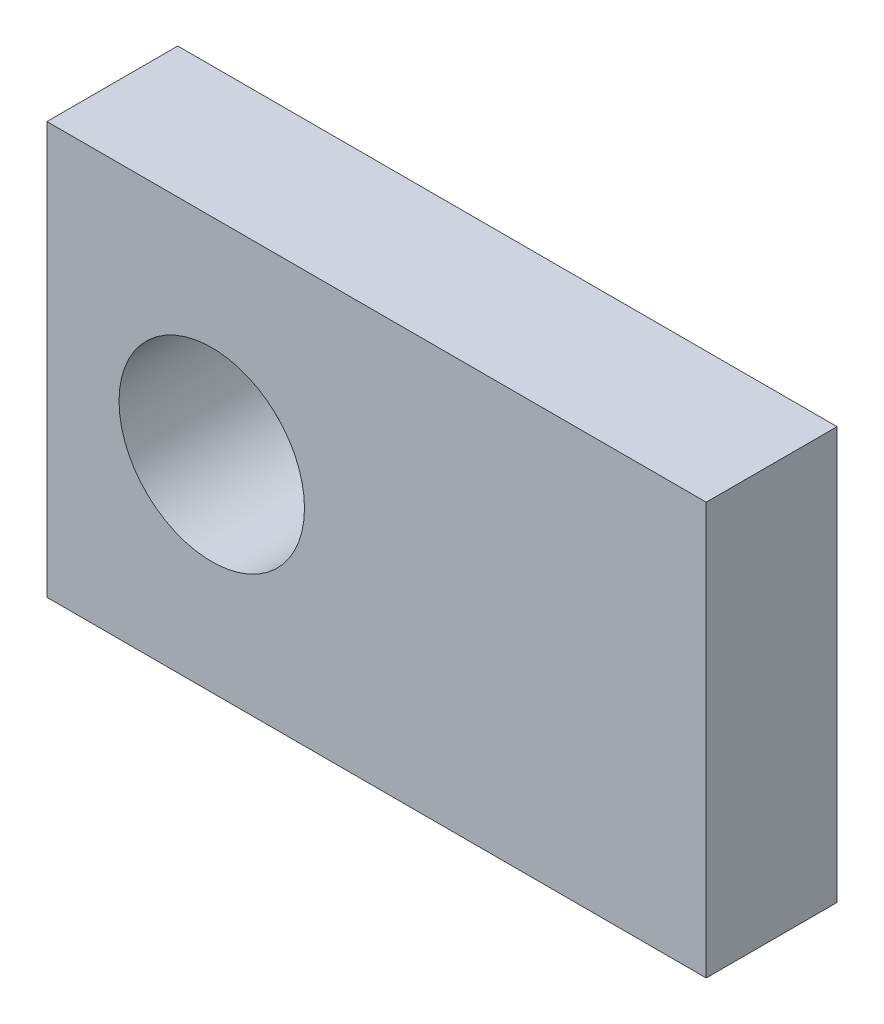
from build123d import *

# Parameters (mm, degrees)
SKETCH1_W            = 16
SKETCH1_H            = 10
BOSS_EXTRUDE1_DEPTH  = 1.5875
M4_CLEARANCE_HOLE1_D = 4.5


with BuildPart() as part:
    # Sketch1 → Boss-Extrude1 (new body, symmetric)
    with BuildSketch(Plane.XY):
        Rectangle(SKETCH1_W, SKETCH1_H)
    extrude(amount=BOSS_EXTRUDE1_DEPTH, both=True)

    # M4 Clearance Hole1 (through all)
    with Locations(Plane.XY.offset(1.5875)):
        with Locations((-4, 0)):
            Hole(M4_CLEARANCE_HOLE1_D / 2)


solid = part.part
